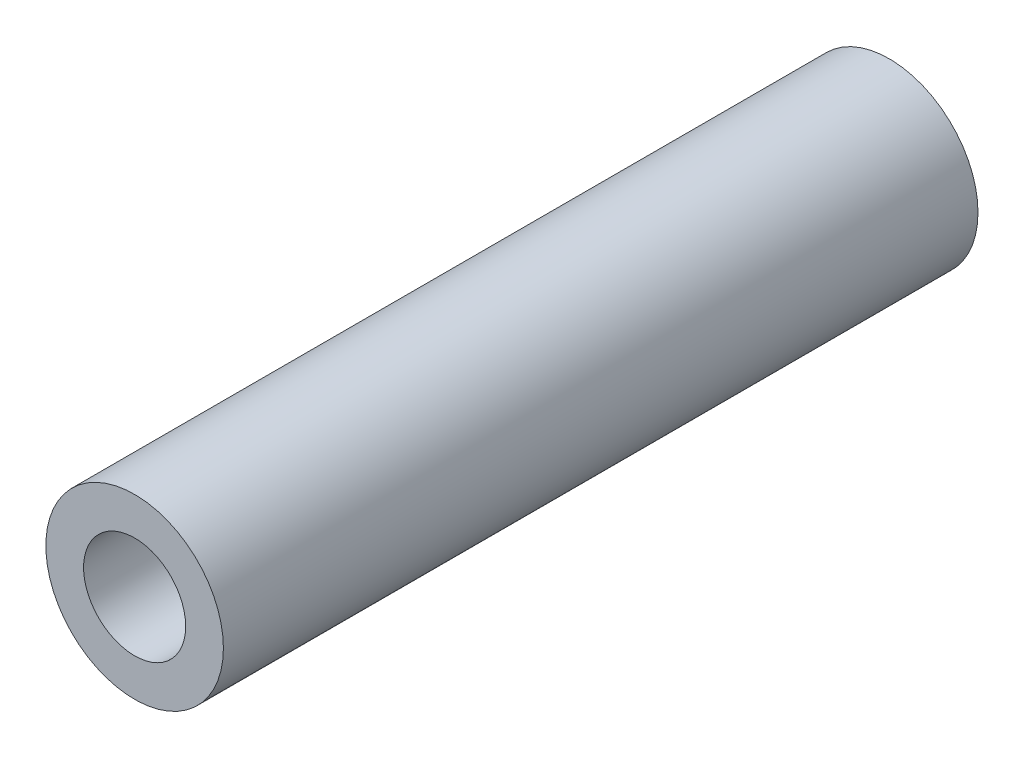
from build123d import *

# Parameters (mm, degrees)
ESQUISSE1_R        = 4
ESQUISSE1_R_2      = 2.3
BOSS_EXTRU_1_DEPTH = 17


with BuildPart() as part:
    # Esquisse1 → Boss.-Extru.1 (new body, symmetric)
    with BuildSketch(Plane.XY):
        Circle(ESQUISSE1_R)
        Circle(ESQUISSE1_R_2, mode=Mode.SUBTRACT)
    extrude(amount=BOSS_EXTRU_1_DEPTH, both=True)


solid = part.part
